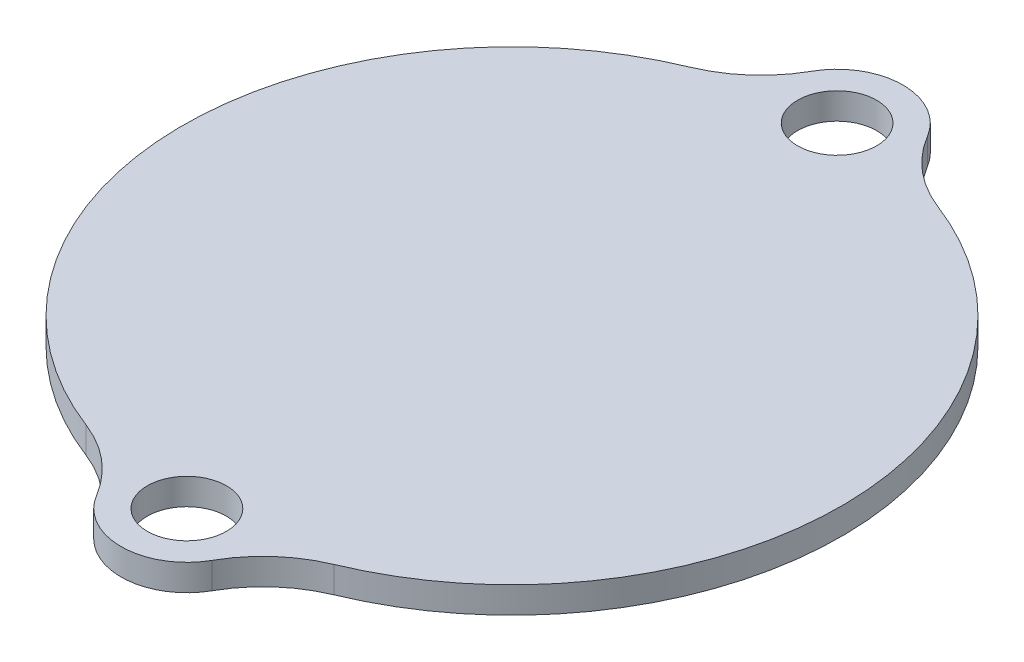
from build123d import *

# Parameters (mm, degrees)
SKETCH1_R           = 3
BOSS_EXTRUDE1_DEPTH = 2


with BuildPart() as part:
    # Sketch1 → Boss-Extrude1 (new body)
    with BuildSketch(Plane(origin=(0, 0, 0), x_dir=(1, 0, 0), z_dir=(0, 1, 0))):
        with BuildLine():
            ThreePointArc((-9.586965908, 23.088743679), (-24.997785997, -0.332708958), (-8.969077844, -23.33571603))
            ThreePointArc((-8.969077844, -23.33571603), (-6.11135377, -25.024258777), (-3.963763689, -27.555191479))
            ThreePointArc((-3.963763689, -27.555191479), (0.399250749, -29.997343196), (4.695723396, -27.439937715))
            ThreePointArc((4.695723396, -27.439937715), (6.775193594, -24.852744798), (9.586965908, -23.088743679))
            ThreePointArc((9.586965908, -23.088743679), (24.997785997, 0.332708958), (8.969077844, 23.33571603))
            ThreePointArc((8.969077844, 23.33571603), (6.11135377, 25.024258777), (3.963763689, 27.555191479))
            ThreePointArc((3.963763689, 27.555191479), (-0.399250749, 29.997343196), (-4.695723396, 27.439937715))
            ThreePointArc((-4.695723396, 27.439937715), (-6.775193594, 24.852744798), (-9.586965908, 23.088743679))
        make_face()
        with Locations((-0.332708958, 24.997785997)):
            Circle(SKETCH1_R, mode=Mode.SUBTRACT)
        with Locations((0.332708958, -24.997785997)):
            Circle(SKETCH1_R, mode=Mode.SUBTRACT)
    extrude(amount=BOSS_EXTRUDE1_DEPTH)


solid = part.part
